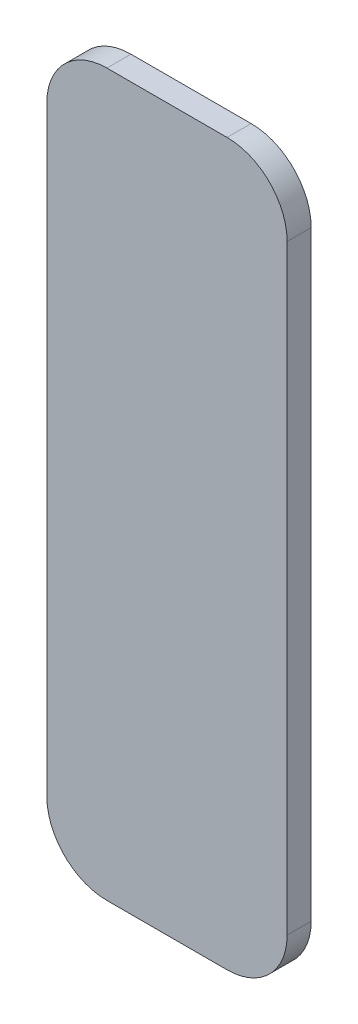
from build123d import *

# Parameters (mm, degrees)
BOSS_EXTRUDE1_DEPTH = 2.54


with BuildPart() as part:
    # Sketch1 → Boss-Extrude1 (new body)
    with BuildSketch(Plane(origin=(0, 0, 0), x_dir=(0, 1, 0), z_dir=(0, 0, 1))):
        with BuildLine():
            Line((6.35, 0), (69.85, 0))
            ThreePointArc((69.85, 0), (74.340128061, 1.859871939), (76.2, 6.35))
            Line((76.2, 6.35), (76.2, 19.05))
            ThreePointArc((76.2, 19.05), (74.340128061, 23.540128061), (69.85, 25.4))
            Line((69.85, 25.4), (6.35, 25.4))
            ThreePointArc((6.35, 25.4), (1.859871939, 23.540128061), (0, 19.05))
            Line((0, 19.05), (0, 6.35))
            ThreePointArc((0, 6.35), (1.859871939, 1.859871939), (6.35, 0))
        make_face()
    extrude(amount=BOSS_EXTRUDE1_DEPTH)


solid = part.part
